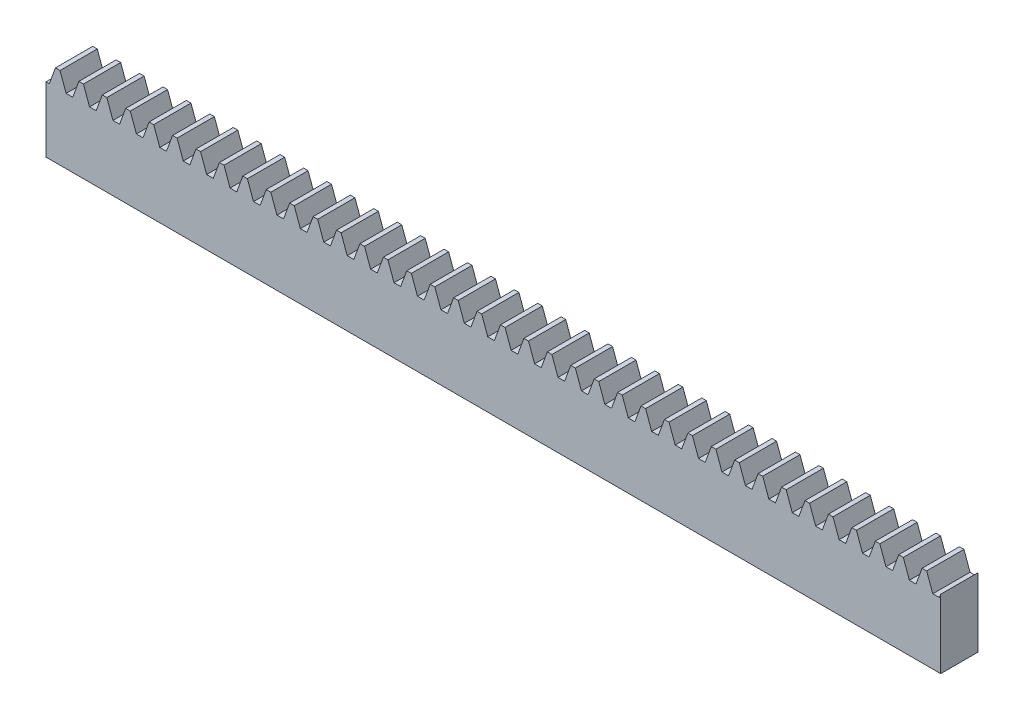
from build123d import *

# Parameters (mm, degrees)
BLANKSKE_W        = 120
BLANKSKE_H        = 11
BLANK_DEPTH       = 5
TOOTHCUTSIM_DEPTH = 121.606799145
TEETHCUTS_COUNT   = 39
TEETHCUTS_PITCH   = 3.14159265


with BuildPart() as part:
    # BlankSke → Blank (new body)
    with BuildSketch(Plane.XY):
        with Locations((60, 5.5)):
            Rectangle(BLANKSKE_W, BLANKSKE_H)
    extrude(amount=-BLANK_DEPTH)

    # TooCutSkeSim → ToothCutSim (cut, through all)
    with BuildSketch(Plane.XY):
        Polygon((0.44443537, 8.75), (-0.44443537, 8.75), (-1.272613241, 11.0254), (1.272613241, 11.0254), align=None)
    toothcutsim = extrude(amount=-TOOTHCUTSIM_DEPTH, mode=Mode.SUBTRACT)

    # TeethCuts: ToothCutSim ×39
    with Locations(*[(i * TEETHCUTS_PITCH, 0, 0) for i in range(1, TEETHCUTS_COUNT)]):
        add(toothcutsim, mode=Mode.SUBTRACT)


solid = part.part
